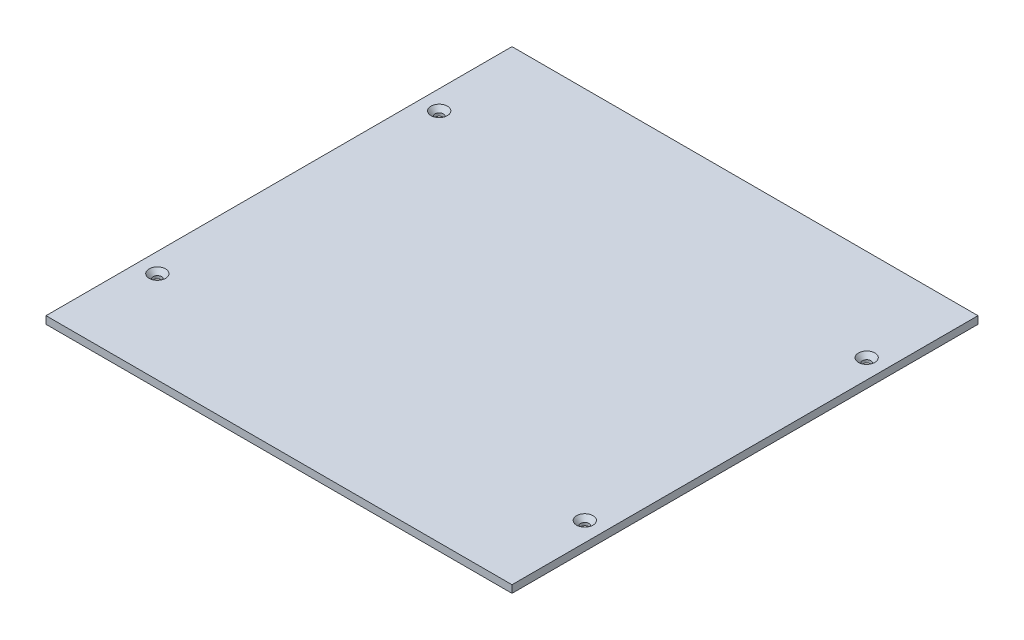
from build123d import *

# Parameters (mm, degrees)
SKETCH1_W                                     = 99.2004
SKETCH1_H                                     = 99.2004
BOSS_EXTRUDE1_DEPTH                           = 1.6002
CSK_FOR_0_FLAT_HEAD_SOCKET_CAP_SCREW1_A_COUNT = 2
CSK_FOR_0_FLAT_HEAD_SOCKET_CAP_SCREW1_A_PITCH = 60
CSK_FOR_0_FLAT_HEAD_SOCKET_CAP_SCRE_2_COUNT   = 2
CSK_FOR_0_FLAT_HEAD_SOCKET_CAP_SCRE_2_PITCH   = 109
CSK_FOR_0_FLAT_HEAD_SOCKET_CAP_SCRE_3_COUNT   = 2
CSK_FOR_0_FLAT_HEAD_SOCKET_CAP_SCRE_3_PITCH   = 91


with BuildPart() as part:
    # Sketch1 → Boss-Extrude1 (new body)
    with BuildSketch(Plane(origin=(0, 0, 0), x_dir=(1, 0, 0), z_dir=(0, 1, 0))):
        with Locations((49.6002, 49.6002)):
            Rectangle(SKETCH1_W, SKETCH1_H)
    extrude(amount=BOSS_EXTRUDE1_DEPTH)

    # Sketch5 → CSK for #0 Flat Head Socket Cap Screw1 (revolve, cut)
    with BuildSketch(Plane(origin=(4.1002, 1.6002, -79.6002), x_dir=(0, 0, 1), z_dir=(1, 0, 0))):
        Polygon((0, 0), (0, 1.6002), (0.889, 1.6002), (0.889, 0.993458156), (1.7526, 0), align=None)
    csk_for_0_flat_head_socket_cap_screw1 = revolve(axis=Axis((4.1002, 7.9502, -79.6002), (0, -1, 0)), mode=Mode.SUBTRACT)

    # CSK for #0 Flat Head Socket Cap Screw1 a: CSK for #0 Flat Head Socket Cap Screw1 ×2
    with Locations(*[(0, 0, i * CSK_FOR_0_FLAT_HEAD_SOCKET_CAP_SCREW1_A_PITCH) for i in range(1, CSK_FOR_0_FLAT_HEAD_SOCKET_CAP_SCREW1_A_COUNT)]):
        add(csk_for_0_flat_head_socket_cap_screw1, mode=Mode.SUBTRACT)

    # CSK for _0 Flat Head Socket Cap Scre 2: CSK for #0 Flat Head Socket Cap Screw1 ×2
    with Locations(*[Vector(0.834862385, 0, 0.550458716) * (i * CSK_FOR_0_FLAT_HEAD_SOCKET_CAP_SCRE_2_PITCH) for i in range(1, CSK_FOR_0_FLAT_HEAD_SOCKET_CAP_SCRE_2_COUNT)]):
        add(csk_for_0_flat_head_socket_cap_screw1, mode=Mode.SUBTRACT)

    # CSK for _0 Flat Head Socket Cap Scre 3: CSK for #0 Flat Head Socket Cap Screw1 ×2
    with Locations(*[(i * CSK_FOR_0_FLAT_HEAD_SOCKET_CAP_SCRE_3_PITCH, 0, 0) for i in range(1, CSK_FOR_0_FLAT_HEAD_SOCKET_CAP_SCRE_3_COUNT)]):
        add(csk_for_0_flat_head_socket_cap_screw1, mode=Mode.SUBTRACT)


solid = part.part
